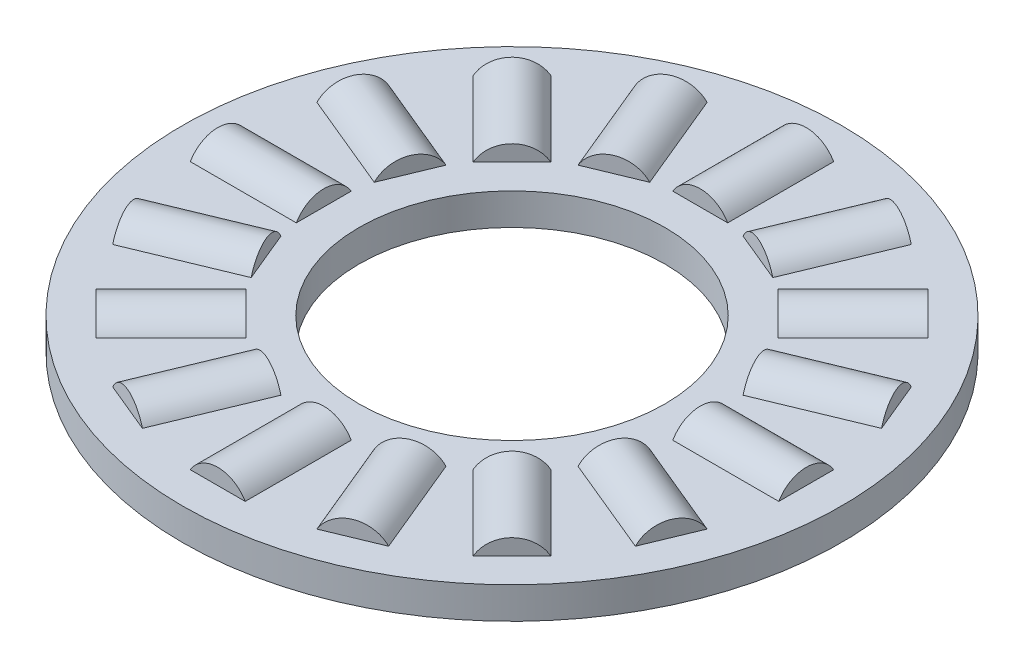
from build123d import *

# Parameters (mm, degrees)
SKETCH5_W         = 5.53085
SKETCH5_H         = 0.9921875
SKETCH3_W         = 3.31851
SKETCH3_H         = 0.9921875
SKETCH2_W         = 3.31851
SKETCH2_H         = 0.9921875
CIRPATTERN1_COUNT = 16
CIRPATTERN1_ANGLE = 337.5
CIRPATTERN2_COUNT = 16


with BuildPart() as part:
    # Sketch5 → Revolve3 (revolve)
    with BuildSketch(Plane(origin=(0, 0, 0), x_dir=(0, 0, -1), z_dir=(1, 0, 0))):
        with Locations((-7.553325, 0)):
            Rectangle(SKETCH5_W, SKETCH5_H)
    revolve(axis=Axis((0, -0.9921875, 0), (0, 1, 0)))

    # Sketch3 → Cut-Revolve1 (revolve, cut)
    with BuildSketch(Plane(origin=(0, 0, 0), x_dir=(0, 0, -1), z_dir=(1, 0, 0))):
        with Locations((-7.553325, 0.49609375)):
            Rectangle(SKETCH3_W, SKETCH3_H)
    cut_revolve1 = revolve(axis=Axis((0, 0, 9.21258), (0, 0, -1)), mode=Mode.SUBTRACT)

    # CirPattern2: Cut-Revolve1 ×16 about axis
    cirpattern2_axis = Axis((0, 0.9921875, 0), (0, -1, 0))
    for i in range(1, CIRPATTERN2_COUNT):
        add(cut_revolve1.rotate(cirpattern2_axis, i * 360 / CIRPATTERN2_COUNT), mode=Mode.SUBTRACT)


with BuildPart() as body_2:
    # Sketch2 → Revolve2 (revolve)
    with BuildSketch(Plane(origin=(0, 0, 0), x_dir=(0, 0, -1), z_dir=(1, 0, 0))):
        with Locations((-7.553325, 0.49609375)):
            Rectangle(SKETCH2_W, SKETCH2_H)
    revolve(axis=Axis((0, 0, 9.21258), (0, 0, -1)))


with BuildPart() as cirpattern1_1:
    # CirPattern1: pattern copy
    add(body_2.part.rotate(Axis((0, 0.9921875, 0), (0, -1, 0)), 1 * CIRPATTERN1_ANGLE / (CIRPATTERN1_COUNT - 1)))


with BuildPart() as cirpattern1_2:
    # CirPattern1: pattern copy
    add(body_2.part.rotate(Axis((0, 0.9921875, 0), (0, -1, 0)), 2 * CIRPATTERN1_ANGLE / (CIRPATTERN1_COUNT - 1)))


with BuildPart() as cirpattern1_3:
    # CirPattern1: pattern copy
    add(body_2.part.rotate(Axis((0, 0.9921875, 0), (0, -1, 0)), 3 * CIRPATTERN1_ANGLE / (CIRPATTERN1_COUNT - 1)))


with BuildPart() as cirpattern1_4:
    # CirPattern1: pattern copy
    add(body_2.part.rotate(Axis((0, 0.9921875, 0), (0, -1, 0)), 4 * CIRPATTERN1_ANGLE / (CIRPATTERN1_COUNT - 1)))


with BuildPart() as cirpattern1_5:
    # CirPattern1: pattern copy
    add(body_2.part.rotate(Axis((0, 0.9921875, 0), (0, -1, 0)), 5 * CIRPATTERN1_ANGLE / (CIRPATTERN1_COUNT - 1)))


with BuildPart() as cirpattern1_6:
    # CirPattern1: pattern copy
    add(body_2.part.rotate(Axis((0, 0.9921875, 0), (0, -1, 0)), 6 * CIRPATTERN1_ANGLE / (CIRPATTERN1_COUNT - 1)))


with BuildPart() as cirpattern1_7:
    # CirPattern1: pattern copy
    add(body_2.part.rotate(Axis((0, 0.9921875, 0), (0, -1, 0)), 7 * CIRPATTERN1_ANGLE / (CIRPATTERN1_COUNT - 1)))


with BuildPart() as cirpattern1_8:
    # CirPattern1: pattern copy
    add(body_2.part.rotate(Axis((0, 0.9921875, 0), (0, -1, 0)), 8 * CIRPATTERN1_ANGLE / (CIRPATTERN1_COUNT - 1)))


with BuildPart() as cirpattern1_9:
    # CirPattern1: pattern copy
    add(body_2.part.rotate(Axis((0, 0.9921875, 0), (0, -1, 0)), 9 * CIRPATTERN1_ANGLE / (CIRPATTERN1_COUNT - 1)))


with BuildPart() as cirpattern1_10:
    # CirPattern1: pattern copy
    add(body_2.part.rotate(Axis((0, 0.9921875, 0), (0, -1, 0)), 10 * CIRPATTERN1_ANGLE / (CIRPATTERN1_COUNT - 1)))


with BuildPart() as cirpattern1_11:
    # CirPattern1: pattern copy
    add(body_2.part.rotate(Axis((0, 0.9921875, 0), (0, -1, 0)), 11 * CIRPATTERN1_ANGLE / (CIRPATTERN1_COUNT - 1)))


with BuildPart() as cirpattern1_12:
    # CirPattern1: pattern copy
    add(body_2.part.rotate(Axis((0, 0.9921875, 0), (0, -1, 0)), 12 * CIRPATTERN1_ANGLE / (CIRPATTERN1_COUNT - 1)))


with BuildPart() as cirpattern1_13:
    # CirPattern1: pattern copy
    add(body_2.part.rotate(Axis((0, 0.9921875, 0), (0, -1, 0)), 13 * CIRPATTERN1_ANGLE / (CIRPATTERN1_COUNT - 1)))


with BuildPart() as cirpattern1_14:
    # CirPattern1: pattern copy
    add(body_2.part.rotate(Axis((0, 0.9921875, 0), (0, -1, 0)), 14 * CIRPATTERN1_ANGLE / (CIRPATTERN1_COUNT - 1)))


with BuildPart() as cirpattern1_15:
    # CirPattern1: pattern copy
    add(body_2.part.rotate(Axis((0, 0.9921875, 0), (0, -1, 0)), 15 * CIRPATTERN1_ANGLE / (CIRPATTERN1_COUNT - 1)))


solid = Compound([part.part, body_2.part, cirpattern1_1.part, cirpattern1_2.part, cirpattern1_3.part, cirpattern1_4.part, cirpattern1_5.part, cirpattern1_6.part, cirpattern1_7.part, cirpattern1_8.part, cirpattern1_9.part, cirpattern1_10.part, cirpattern1_11.part, cirpattern1_12.part, cirpattern1_13.part, cirpattern1_14.part, cirpattern1_15.part])
